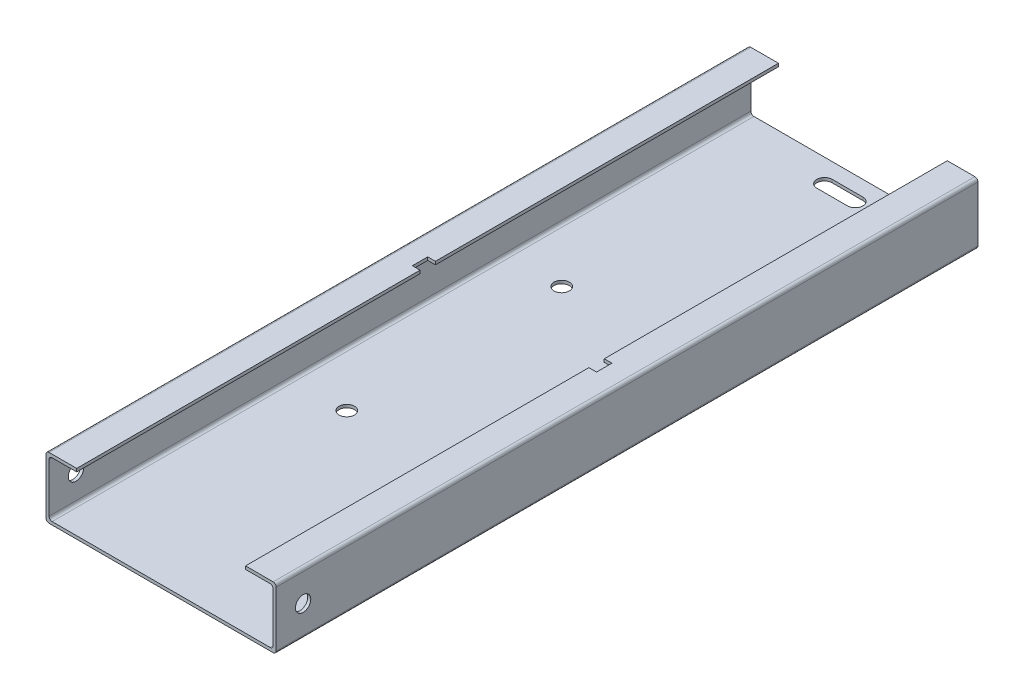
from build123d import *

# Parameters (mm, degrees)
SALIENTE_EXTRUIR2_DEPTH = 228.6
REDONDEO1_R             = 2
CROQUIS3_R              = 5
CORTAR_EXTRUIR1_DEPTH   = 151
CROQUIS4_W              = 5
CROQUIS4_H              = 10
CORTAR_EXTRUIR2_DEPTH   = 10
CROQUIS5_R              = 5
CORTAR_EXTRUIR3_DEPTH   = 10


with BuildPart() as part:
    # Croquis2 → Saliente-Extruir2 (new body, symmetric)
    with BuildSketch(Plane.XY):
        Polygon((-75, 20), (-55, 20), (-55, 18), (-73, 18), (-73, -18), (73, -18), (73, 18), (55, 18), (55, 20), (75, 20), (75, -20), (-75, -20), align=None)
    extrude(amount=SALIENTE_EXTRUIR2_DEPTH, both=True)

    # Redondeo1
    redondeo1_edges = [part.edges().sort_by_distance(p)[0] for p in [
        (75, 20, 0),
        (75, -20, 0),
        (-75, -20, 0),
        (-75, 20, 0),
        (-73, 18, 0),
        (-73, -18, 0),
        (73, -18, 0),
        (73, 18, 0),
    ]]
    fillet(redondeo1_edges, radius=REDONDEO1_R)

    # Croquis3 → Cortar-Extruir1 (cut, through all)
    with BuildSketch(Plane(origin=(75, 0, 0), x_dir=(0, 0, -1), z_dir=(1, 0, 0))):
        with Locations((-211.1, 0)):
            Circle(CROQUIS3_R)
    extrude(amount=-CORTAR_EXTRUIR1_DEPTH, mode=Mode.SUBTRACT)

    # Croquis4 → Cortar-Extruir2 (cut)
    with BuildSketch(Plane(origin=(0, 20, 0), x_dir=(1, 0, 0), z_dir=(0, 1, 0))):
        with Locations((-57.5, 0.1)):
            Rectangle(CROQUIS4_W, CROQUIS4_H)
        with Locations((57.5, 0.1)):
            Rectangle(CROQUIS4_W, CROQUIS4_H)
    extrude(amount=-CORTAR_EXTRUIR2_DEPTH, mode=Mode.SUBTRACT)

    # Croquis5 → Cortar-Extruir3 (cut)
    with BuildSketch(Plane.XZ.offset(20)):
        with Locations((-37.644195885, -70)):
            Circle(CROQUIS5_R)
        with Locations((32.355804115, -70)):
            Circle(CROQUIS5_R)
        with Locations((32.355804115, 70)):
            Circle(CROQUIS5_R)
        with Locations((-37.644195885, 70)):
            Circle(CROQUIS5_R)
        with BuildLine():
            Line((-10, -208.6), (10, -208.6))
            ThreePointArc((10, -208.6), (15, -213.6), (10, -218.6))
            Line((10, -218.6), (-10, -218.6))
            ThreePointArc((-10, -218.6), (-15, -213.6), (-10, -208.6))
        make_face()
    extrude(amount=-CORTAR_EXTRUIR3_DEPTH, mode=Mode.SUBTRACT)


solid = part.part
